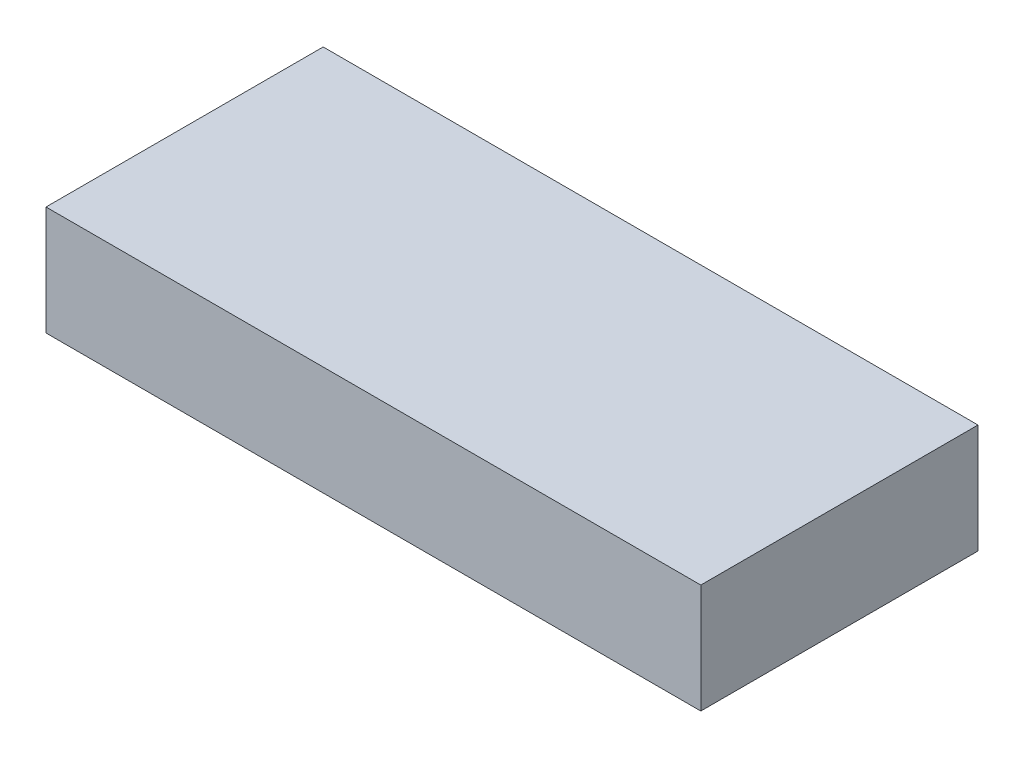
from build123d import *

# Parameters (mm, degrees)
SKETCH1_W           = 60
SKETCH1_H           = 25.4
BOSS_EXTRUDE1_DEPTH = 5


with BuildPart() as part:
    # Sketch1 → Boss-Extrude1 (new body, symmetric)
    with BuildSketch(Plane(origin=(0, 0, 0), x_dir=(1, 0, 0), z_dir=(0, 1, 0))):
        Rectangle(SKETCH1_W, SKETCH1_H)
    extrude(amount=BOSS_EXTRUDE1_DEPTH, both=True)


solid = part.part
